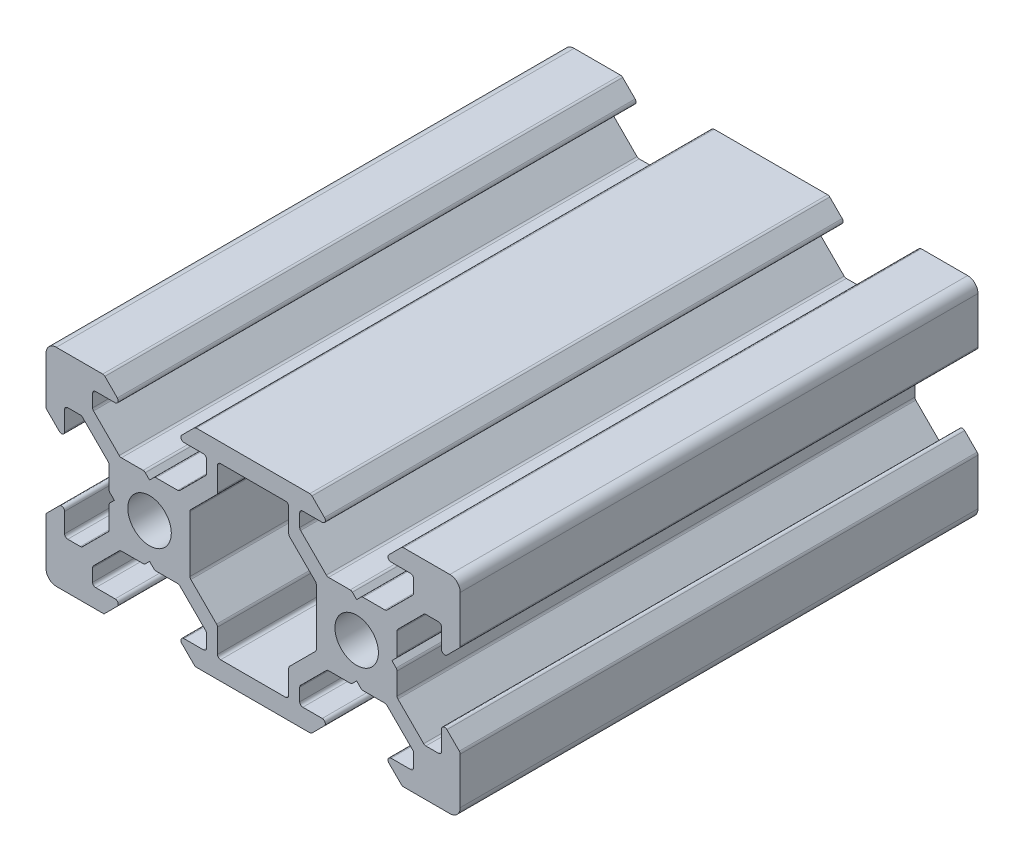
from build123d import *

# Parameters (mm, degrees)
SKETCH_1_R      = 2.1
EXTRUDE_1_DEPTH = 50
FILLET_1_R      = 1
FILLET_2_R      = 0.3


with BuildPart() as part:
    # Эскиз1 → Бобышка-Вытянуть1 (new body)
    with BuildSketch(Plane.XY):
        Polygon((-10, -10), (-10, -4.4), (-8.2, -2.6), (-8.2, -5.499339828), (-6.56, -5.499339828), (-3.900660172, -2.84), (-3.900660172, -0.5), (-3.400660172, 0), (-3.900660172, 0.5), (-3.900660172, 2.84), (-6.56, 5.499339828), (-8.2, 5.499339828), (-8.2, 2.6), (-10, 4.4), (-10, 10), (-4.4, 10), (-2.6, 8.2), (-5.499339828, 8.2), (-5.499339828, 6.56), (-2.84, 3.900660172), (-0.5, 3.900660172), (0, 3.400660172), (0.5, 3.900660172), (2.84, 3.900660172), (5.499339828, 6.56), (5.499339828, 8.2), (2.6, 8.2), (4.4, 10), (15.6, 10), (17.4, 8.2), (14.500660172, 8.2), (14.500660172, 6.56), (17.16, 3.900660172), (19.5, 3.900660172), (20, 3.400660172), (20.5, 3.900660172), (22.84, 3.900660172), (25.499339828, 6.56), (25.499339828, 8.2), (22.6, 8.2), (24.4, 10), (30, 10), (30, 4.4), (28.2, 2.6), (28.2, 5.499339828), (26.56, 5.499339828), (23.900660172, 2.84), (23.900660172, 0.5), (23.400660172, 0), (23.900660172, -0.5), (23.900660172, -2.84), (26.56, -5.499339828), (28.2, -5.499339828), (28.2, -2.6), (30, -4.4), (30, -10), (24.4, -10), (22.6, -8.2), (25.499339828, -8.2), (25.499339828, -6.56), (22.84, -3.900660172), (20.5, -3.900660172), (20, -3.400660172), (19.5, -3.900660172), (17.16, -3.900660172), (14.500660172, -6.56), (14.500660172, -8.2), (17.4, -8.2), (15.6, -10), (4.4, -10), (2.6, -8.2), (5.499339828, -8.2), (5.499339828, -6.56), (2.84, -3.900660172), (0.5, -3.900660172), (0, -3.400660172), (-0.5, -3.900660172), (-2.84, -3.900660172), (-5.499339828, -6.56), (-5.499339828, -8.2), (-2.6, -8.2), (-4.4, -10), align=None)
        Circle(SKETCH_1_R, mode=Mode.SUBTRACT)
        with Locations(Location((20, 0, 0), (0, 0, 180))):  # turned: the seam where the file's is
            Circle(SKETCH_1_R, mode=Mode.SUBTRACT)
        Polygon((3.900660172, -0.5), (3.900660172, 0.5), (3.900660172, 2.84), (6.56, 5.499339828), (6.56, 8.2), (13.44, 8.2), (13.44, 5.499339828), (16.099339828, 2.84), (16.099339828, 0.5), (16.099339828, -0.5), (16.099339828, -2.84), (13.44, -5.499339828), (13.44, -8.2), (6.56, -8.2), (6.56, -5.499339828), (3.900660172, -2.84), align=None, mode=Mode.SUBTRACT)
    extrude(amount=EXTRUDE_1_DEPTH)

    # Скругление1
    fillet_1_edges = [part.edges().sort_by_distance(p)[0] for p in [
        (-10, -10, 25),
        (-10, 10, 25),
        (30, 10, 25),
        (30, -10, 25),
    ]]
    fillet(fillet_1_edges, radius=FILLET_1_R)

    # Скругление2
    fillet_2_edges = [part.edges().sort_by_distance(p)[0] for p in [
        (-10, -4.4, 25),
        (-8.2, -2.6, 25),
        (-8.2, -5.499339828, 25),
        (-6.56, -5.499339828, 25),
        (-3.900660172, -2.84, 25),
        (-3.900660172, -0.5, 25),
        (-3.900660172, 0.5, 25),
        (-3.900660172, 2.84, 25),
        (-6.56, 5.499339828, 25),
        (-8.2, 5.499339828, 25),
        (-8.2, 2.6, 25),
        (-10, 4.4, 25),
        (-4.4, 10, 25),
        (-2.6, 8.2, 25),
        (-5.499339828, 8.2, 25),
        (-5.499339828, 6.56, 25),
        (-2.84, 3.900660172, 25),
        (-0.5, 3.900660172, 25),
        (0.5, 3.900660172, 25),
        (2.84, 3.900660172, 25),
        (5.499339828, 6.56, 25),
        (5.499339828, 8.2, 25),
        (2.6, 8.2, 25),
        (4.4, 10, 25),
        (15.6, 10, 25),
        (17.4, 8.2, 25),
        (14.500660172, 8.2, 25),
        (14.500660172, 6.56, 25),
        (17.16, 3.900660172, 25),
        (19.5, 3.900660172, 25),
        (20.5, 3.900660172, 25),
        (22.84, 3.900660172, 25),
        (25.499339828, 6.56, 25),
        (25.499339828, 8.2, 25),
        (22.6, 8.2, 25),
        (24.4, 10, 25),
        (30, 4.4, 25),
        (28.2, 2.6, 25),
        (28.2, 5.499339828, 25),
        (26.56, 5.499339828, 25),
        (23.900660172, 2.84, 25),
        (23.900660172, 0.5, 25),
        (23.900660172, -0.5, 25),
        (23.900660172, -2.84, 25),
        (26.56, -5.499339828, 25),
        (28.2, -5.499339828, 25),
        (28.2, -2.6, 25),
        (30, -4.4, 25),
        (24.4, -10, 25),
        (22.6, -8.2, 25),
        (25.499339828, -8.2, 25),
        (25.499339828, -6.56, 25),
        (22.84, -3.900660172, 25),
        (20.5, -3.900660172, 25),
        (19.5, -3.900660172, 25),
        (17.16, -3.900660172, 25),
        (14.500660172, -6.56, 25),
        (14.500660172, -8.2, 25),
        (17.4, -8.2, 25),
        (15.6, -10, 25),
        (4.4, -10, 25),
        (2.6, -8.2, 25),
        (5.499339828, -8.2, 25),
        (5.499339828, -6.56, 25),
        (2.84, -3.900660172, 25),
        (0.5, -3.900660172, 25),
        (-0.5, -3.900660172, 25),
        (-2.84, -3.900660172, 25),
        (-5.499339828, -6.56, 25),
        (-5.499339828, -8.2, 25),
        (-2.6, -8.2, 25),
        (6.56, -8.2, 25),
        (13.44, -8.2, 25),
        (13.44, -5.499339828, 25),
        (16.099339828, -2.84, 25),
        (16.099339828, 2.84, 25),
        (13.44, 5.499339828, 25),
        (13.44, 8.2, 25),
        (6.56, 8.2, 25),
        (6.56, 5.499339828, 25),
        (3.900660172, 2.84, 25),
        (3.900660172, -2.84, 25),
        (6.56, -5.499339828, 25),
    ]]
    fillet(fillet_2_edges, radius=FILLET_2_R)


solid = part.part
